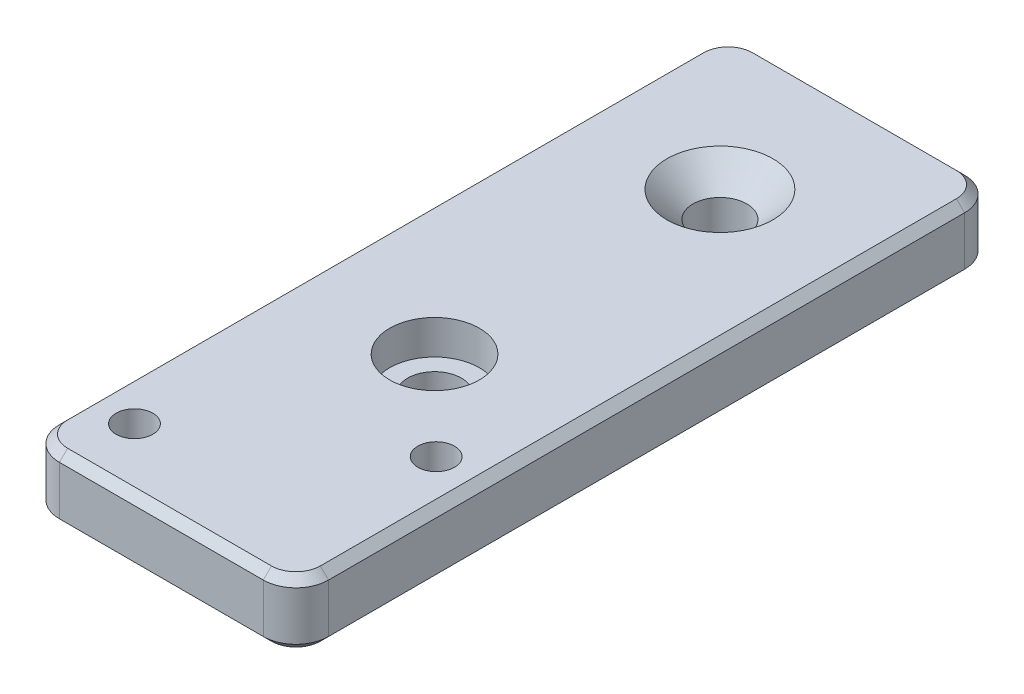
from build123d import *

# Parameters (mm, degrees)
SKETCH1_W           = 33
SKETCH1_H           = 86
BOSS_EXTRUDE1_DEPTH = 8
FILLET1_R           = 4
CHAMFER1_SIZE       = 1
SKETCH2_R           = 3.3
SKETCH2_R_2         = 2.25
CUT_EXTRUDE1_DEPTH  = 8
SKETCH3_R           = 5.5
CUT_EXTRUDE2_DEPTH  = 4.2
CHAMFER3_SIZE       = 3.2
SKETCH4_R           = 4
CUT_EXTRUDE3_DEPTH  = 4.4


with BuildPart() as part:
    # Sketch1 → Boss-Extrude1 (new body)
    with BuildSketch(Plane(origin=(0, 0, 0), x_dir=(1, 0, 0), z_dir=(0, 1, 0))):
        Rectangle(SKETCH1_W, SKETCH1_H)
    extrude(amount=BOSS_EXTRUDE1_DEPTH)

    # Fillet1
    fillet1_edges = [part.edges().sort_by_distance(p)[0] for p in [
        (16.5, 4, 43),
        (-16.5, 4, 43),
        (-16.5, 4, -43),
        (16.5, 4, -43),
    ]]
    fillet(fillet1_edges, radius=FILLET1_R)

    # Chamfer1
    chamfer1_edges = [part.edges().sort_by_distance(p)[0] for p in [
        (-16.5, 0, 0),
        (-16.5, 8, 0),
        (16.5, 0, 0),
        (0, 0, 43),
        (0, 0, -43),
        (15.328427125, 0, 41.828427125),
        (-15.328427125, 0, 41.828427125),
        (15.328427125, 0, -41.828427125),
        (-15.328427125, 0, -41.828427125),
        (0, 8, -43),
        (16.5, 8, 0),
        (0, 8, 43),
        (15.328427125, 8, 41.828427125),
        (-15.328427125, 8, 41.828427125),
        (15.328427125, 8, -41.828427125),
        (-15.328427125, 8, -41.828427125),
    ]]
    chamfer(chamfer1_edges, length=CHAMFER1_SIZE)

    # Sketch2 → Cut-Extrude1 (cut)
    with BuildSketch(Plane(origin=(0, 8, 0), x_dir=(1, 0, 0), z_dir=(0, 1, 0))):
        with Locations((0, 25.5)):
            Circle(SKETCH2_R)
        with Locations((0, -9.5)):
            Circle(SKETCH2_R)
        with Locations((11, -20.3)):
            Circle(SKETCH2_R_2)
        with Locations((-11, -35.3)):
            Circle(SKETCH2_R_2)
    extrude(amount=-CUT_EXTRUDE1_DEPTH, mode=Mode.SUBTRACT)

    # Sketch3 → Cut-Extrude2 (cut)
    with BuildSketch(Plane(origin=(0, 8, 0), x_dir=(1, 0, 0), z_dir=(0, 1, 0))):
        with Locations((0, -9.5)):
            Circle(SKETCH3_R)
    extrude(amount=-CUT_EXTRUDE2_DEPTH, mode=Mode.SUBTRACT)

    # Chamfer3
    chamfer3_edges = [part.edges().sort_by_distance(p)[0] for p in [
        (-3.3, 8, -25.5),
    ]]
    chamfer(chamfer3_edges, length=CHAMFER3_SIZE)

    # Sketch4 → Cut-Extrude3 (cut)
    with BuildSketch(Plane.XZ):
        with Locations((11, 20.3)):
            Circle(SKETCH4_R)
        with Locations((-11, 35.3)):
            Circle(SKETCH4_R)
    extrude(amount=-CUT_EXTRUDE3_DEPTH, mode=Mode.SUBTRACT)


solid = part.part
